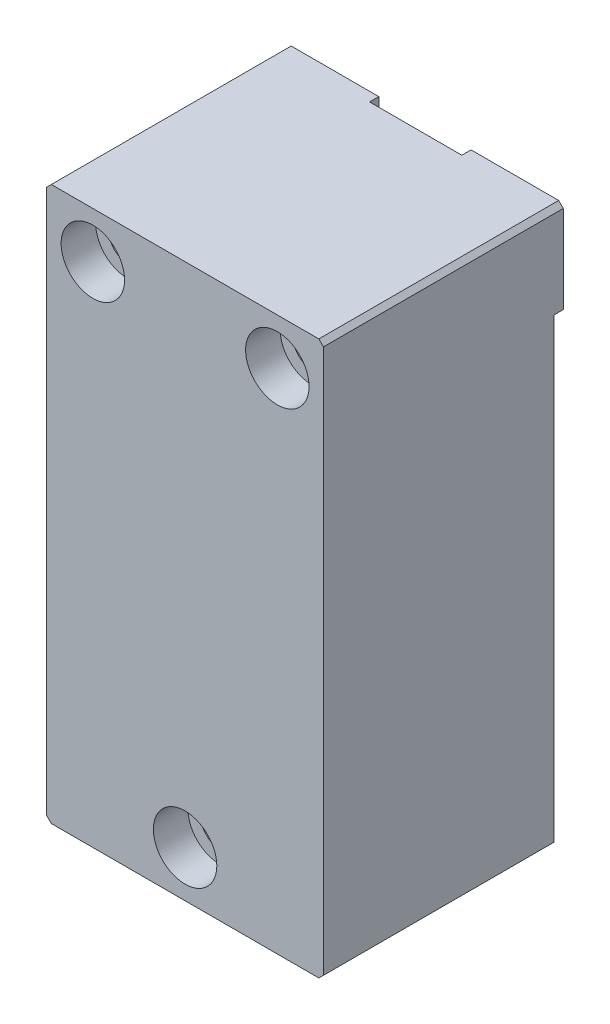
from build123d import *

# Parameters (mm, degrees)
SKETCH1_W                                        = 76.2
SKETCH1_H                                        = 152.4
EXTRUDE1_DEPTH                                   = 63.5
SKETCH4_W                                        = 25.4
SKETCH4_H                                        = 25.4
EXTRUDE2_DEPTH                                   = 2.54
CBORE_FOR_3_8_SOCKET_HEAD_CAP_SCREW1_D           = 10.31748
CBORE_FOR_3_8_SOCKET_HEAD_CAP_SCREW1_CBORE_D     = 17.4752
CBORE_FOR_3_8_SOCKET_HEAD_CAP_SCREW1_CBORE_DEPTH = 9.525
CHAMFER2_SIZE                                    = 1.27


with BuildPart() as part:
    # Sketch1 → Extrude1 (new body)
    with BuildSketch(Plane.XY):
        with Locations((0, -38.1)):
            Rectangle(SKETCH1_W, SKETCH1_H)
    extrude(amount=EXTRUDE1_DEPTH)

    # Sketch4 → Extrude2 (add)
    with BuildSketch(Plane(origin=(0, 0, 0), x_dir=(-1, 0, 0), z_dir=(0, 0, -1))):
        with Locations((-25.4, 25.4)):
            Rectangle(SKETCH4_W, SKETCH4_H)
        with Locations((25.4, 25.4)):
            Rectangle(SKETCH4_W, SKETCH4_H)
        with Locations((0, -101.6)):
            Rectangle(SKETCH4_W, SKETCH4_H)
    extrude(amount=EXTRUDE2_DEPTH)

    # CBORE for 3/8 Socket Head Cap Screw1 (through all)
    with Locations(Plane.XY.offset(63.5)):
        with Locations((-25.4, 25.4), (25.4, 25.4), (0, -101.6)):
            CounterBoreHole(CBORE_FOR_3_8_SOCKET_HEAD_CAP_SCREW1_D / 2, CBORE_FOR_3_8_SOCKET_HEAD_CAP_SCREW1_CBORE_D / 2, CBORE_FOR_3_8_SOCKET_HEAD_CAP_SCREW1_CBORE_DEPTH)

    # Chamfer2
    chamfer2_edges = [part.edges().sort_by_distance(p)[0] for p in [
        (-38.1, 38.1, 30.48),
        (38.1, 38.1, 30.48),
        (38.1, -114.3, 31.75),
        (-38.1, -114.3, 31.75),
    ]]
    chamfer(chamfer2_edges, length=CHAMFER2_SIZE)


solid = part.part
